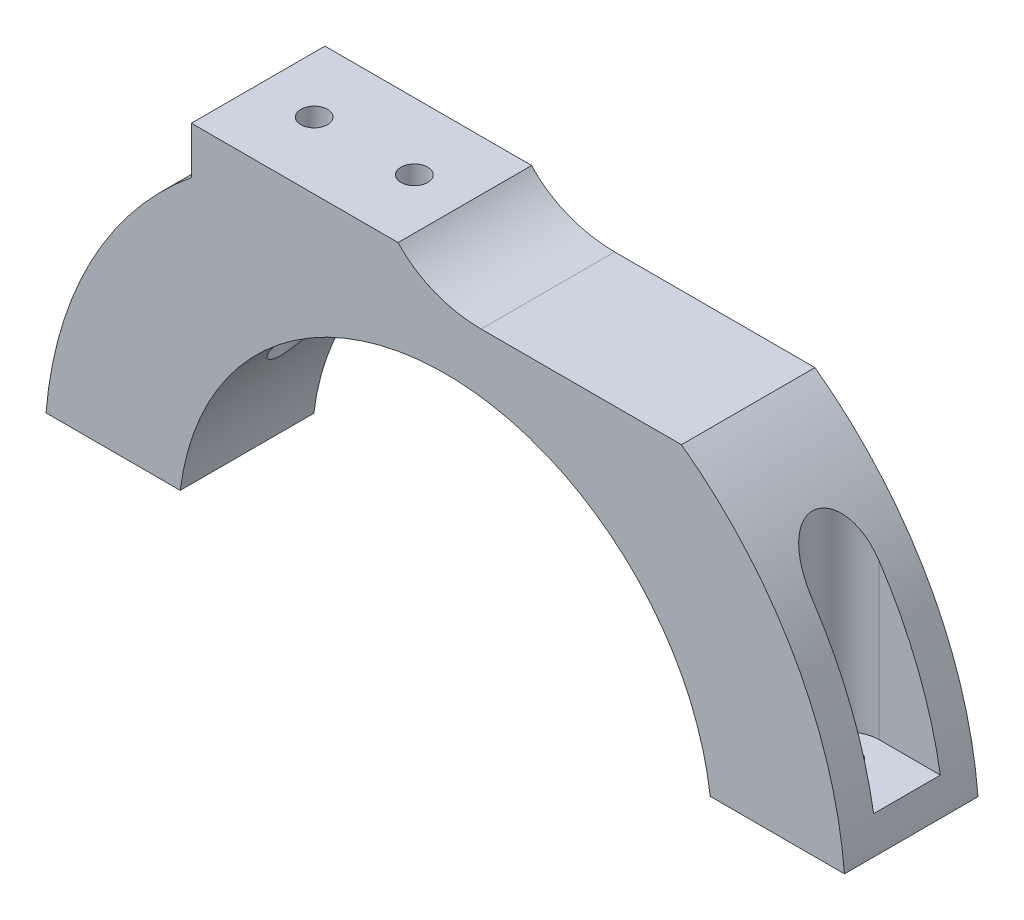
from build123d import *

# Parameters (mm, degrees)
BOSS_EXTRUDE1_DEPTH = 20
SKETCH2_R           = 2.25
CUT_EXTRUDE1_DEPTH  = 79
CUT_EXTRUDE4_DEPTH  = 59
SKETCH7_R           = 2
BOSS_EXTRUDE3_DEPTH = 10
CUT_EXTRUDE5_DEPTH  = 23
BOSS_EXTRUDE2_DEPTH = 20
SKETCH4_R           = 2.25
CUT_EXTRUDE2_DEPTH  = 30
CUT_EXTRUDE6_DEPTH  = 36
SKETCH10_R          = 2
BOSS_EXTRUDE4_DEPTH = 5
SKETCH12_W          = 120
SKETCH12_H          = 5
CUT_EXTRUDE7_DEPTH  = 20


with BuildPart() as part:
    # Sketch1 → Boss-Extrude1 (new body)
    with BuildSketch(Plane.XY):
        with BuildLine():
            Line((-60, 0), (-40, 0))
            ThreePointArc((-40, 0), (-28.284271247, 28.284271247), (0, 40))
            Line((0, 40), (0, 48.461538462))
            Line((0, 48.461538462), (-35.376253193, 48.461538462))
            ThreePointArc((-35.376253193, 48.461538462), (-53.491004812, 27.179264233), (-60, 0))
        make_face()
    boss_extrude1 = extrude(amount=BOSS_EXTRUDE1_DEPTH)

    # Sketch2 → Cut-Extrude1 (cut)
    with BuildSketch(Plane.XZ):
        with Locations((-50, 10)):
            Circle(SKETCH2_R)
    cut_extrude1 = extrude(amount=-CUT_EXTRUDE1_DEPTH, mode=Mode.SUBTRACT)

    # Sketch6 → Cut-Extrude4 (cut)
    with BuildSketch(Plane.XZ):
        with BuildLine():
            Line((-60, 5), (-50, 5))
            ThreePointArc((-50, 5), (-55, 10), (-50, 15))
            Line((-50, 15), (-60, 15))
            Line((-60, 15), (-60, 5))
        make_face()
        with BuildLine():
            ThreePointArc((-50, 15), (-55, 10), (-50, 5))
            Line((-50, 5), (-50, 7.75))
            ThreePointArc((-50, 7.75), (-52.25, 10), (-50, 12.25))
            Line((-50, 12.25), (-50, 15))
        make_face()
        with BuildLine():
            Line((-50, 7.75), (-50, 5))
            ThreePointArc((-50, 5), (-46.464466094, 6.464466094), (-45, 10))
            ThreePointArc((-45, 10), (-46.464466094, 13.535533906), (-50, 15))
            Line((-50, 15), (-50, 12.25))
            ThreePointArc((-50, 12.25), (-48.409009742, 11.590990258), (-47.75, 10))
            ThreePointArc((-47.75, 10), (-48.409009742, 8.409009742), (-50, 7.75))
        make_face()
    cut_extrude4 = extrude(amount=-CUT_EXTRUDE4_DEPTH, mode=Mode.SUBTRACT)

    # Sketch7 → Boss-Extrude3 (add)
    with BuildSketch(Plane.XZ):
        with BuildLine():
            Line((-50, 15), (-60, 15))
            Line((-60, 15), (-60, 5))
            Line((-60, 5), (-50, 5))
            ThreePointArc((-50, 5), (-45, 10), (-50, 15))
        make_face()
        with Locations((-50, 10)):
            Circle(SKETCH7_R, mode=Mode.SUBTRACT)
    boss_extrude3 = extrude(amount=-BOSS_EXTRUDE3_DEPTH)

    # Sketch8 → Cut-Extrude5 (cut)
    with BuildSketch(Plane.XY.offset(20)):
        with BuildLine():
            Line((-64.996039314, 0), (-60, 0))
            ThreePointArc((-60, 0), (-59.578019695, 7.10348993), (-58.31801436, 14.107062099))
            Line((-58.31801436, 14.107062099), (-63.173999234, 15.28171938))
            ThreePointArc((-63.173999234, 15.28171938), (-64.538921839, 7.694978513), (-64.996039314, 0))
        make_face()
    cut_extrude5 = extrude(amount=-CUT_EXTRUDE5_DEPTH, mode=Mode.SUBTRACT)

    # Mirror1: Boss-Extrude1, Cut-Extrude1, Cut-Extrude4, Boss-Extrude3, Cut-Extrude5 across plane
    add(boss_extrude1.mirror(Plane(origin=(0, 0, 20), x_dir=(0, 0, 1), z_dir=(1, 0, 0))))
    add(cut_extrude1.mirror(Plane(origin=(0, 0, 20), x_dir=(0, 0, 1), z_dir=(1, 0, 0))), mode=Mode.SUBTRACT)
    add(cut_extrude4.mirror(Plane(origin=(0, 0, 20), x_dir=(0, 0, 1), z_dir=(1, 0, 0))), mode=Mode.SUBTRACT)
    add(boss_extrude3.mirror(Plane(origin=(0, 0, 20), x_dir=(0, 0, 1), z_dir=(1, 0, 0))))
    add(cut_extrude5.mirror(Plane(origin=(0, 0, 20), x_dir=(0, 0, 1), z_dir=(1, 0, 0))), mode=Mode.SUBTRACT)

    # Sketch3 → Boss-Extrude2 (add)
    with BuildSketch(Plane(origin=(0, 0, 0), x_dir=(-1, 0, 0), z_dir=(0, 0, -1))):
        with BuildLine():
            add(Edge.make_bspline(
                [(-5.376253193, 48.461538462), (2.596156859, 48.461538462), (7.056491998, 53.461538462)],
                knots=[4.71238898, 4.71238898, 4.71238898, 5.689437437, 5.689437437, 5.689437437], degree=2, weights=[1, 0.883026434, 1]))
            Line((-5.376253193, 48.461538462), (35.376253193, 48.461538462))
            ThreePointArc((35.376253193, 48.461538462), (36.710520922, 47.458799538), (38.016381278, 46.419335998))
            Line((38.016381278, 46.419335998), (38.016381278, 53.461538462))
            Line((38.016381278, 53.461538462), (7.056491998, 53.461538462))
        make_face()
    extrude(amount=-BOSS_EXTRUDE2_DEPTH)

    # Sketch4 → Cut-Extrude2 (cut)
    with BuildSketch(Plane(origin=(0, 53.461538462, 0), x_dir=(1, 0, 0), z_dir=(0, 1, 0))):
        with Locations((-29.623746807, -10)):
            Circle(SKETCH4_R)
        with Locations((-14.623746807, -10)):
            Circle(SKETCH4_R)
    extrude(amount=-CUT_EXTRUDE2_DEPTH, mode=Mode.SUBTRACT)

    # Sketch9 → Cut-Extrude6 (cut)
    with BuildSketch(Plane(origin=(0, 53.461538462, 0), x_dir=(1, 0, 0), z_dir=(0, 1, 0))):
        with BuildLine():
            Line((-29.623746807, -5), (-14.623746807, -5))
            ThreePointArc((-14.623746807, -5), (-9.623746807, -10), (-14.623746807, -15))
            Line((-14.623746807, -15), (-29.623746807, -15))
            ThreePointArc((-29.623746807, -15), (-34.623746807, -10), (-29.623746807, -5))
        make_face()
    extrude(amount=-CUT_EXTRUDE6_DEPTH, mode=Mode.SUBTRACT)

    # Sketch10 → Boss-Extrude4 (add)
    with BuildSketch(Plane(origin=(0, 53.461538462, 0), x_dir=(1, 0, 0), z_dir=(0, 1, 0))):
        with BuildLine():
            Line((-29.623746807, -5), (-14.623746807, -5))
            ThreePointArc((-14.623746807, -5), (-9.623746807, -10), (-14.623746807, -15))
            Line((-14.623746807, -15), (-29.623746807, -15))
            ThreePointArc((-29.623746807, -15), (-34.623746807, -10), (-29.623746807, -5))
        make_face()
        with Locations((-29.623746807, -10)):
            Circle(SKETCH10_R, mode=Mode.SUBTRACT)
        with Locations((-14.623746807, -10)):
            Circle(SKETCH10_R, mode=Mode.SUBTRACT)
    extrude(amount=-BOSS_EXTRUDE4_DEPTH)

    # Sketch12 → Cut-Extrude7 (cut)
    with BuildSketch(Plane(origin=(0, 0, 0), x_dir=(-1, 0, 0), z_dir=(0, 0, -1))):
        with Locations((0, 2.5)):
            Rectangle(SKETCH12_W, SKETCH12_H)
    extrude(amount=-CUT_EXTRUDE7_DEPTH, mode=Mode.SUBTRACT)


solid = part.part
